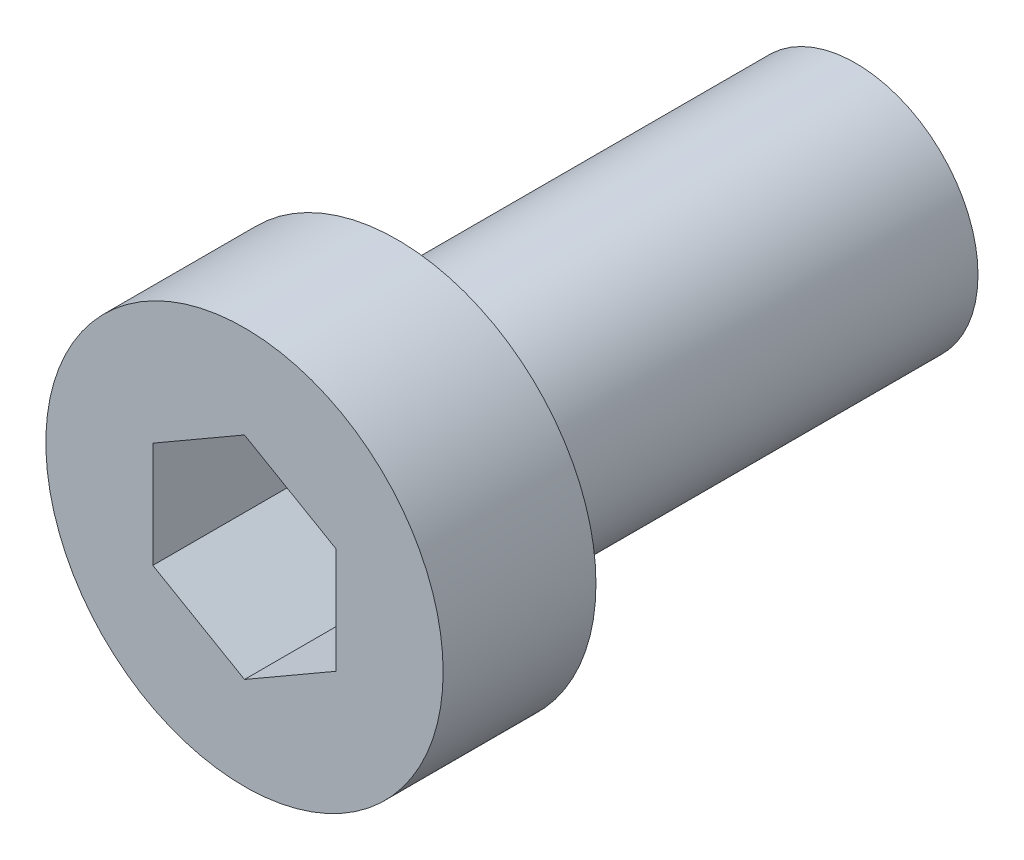
from build123d import *

# Parameters (mm, degrees)
SKETCH1_R           = 6.5
BASE_EXTRUDE_DEPTH  = 5
SKETCH2_R           = 4
BOSS_EXTRUDE1_DEPTH = 15
CUT_EXTRUDE1_DEPTH  = 5


with BuildPart() as part:
    # Sketch1 → Base-Extrude (new body)
    with BuildSketch(Plane.XY):
        Circle(SKETCH1_R)
    extrude(amount=BASE_EXTRUDE_DEPTH)

    # Sketch2 → Boss-Extrude1 (add)
    with BuildSketch(Plane(origin=(0, 0, 0), x_dir=(-1, 0, 0), z_dir=(0, 0, -1))):
        Circle(SKETCH2_R)
    extrude(amount=BOSS_EXTRUDE1_DEPTH)

    # Sketch3 → Cut-Extrude1 (cut)
    with BuildSketch(Plane.XY.offset(5)):
        Polygon((0, 3.464101615), (-3, 1.732050808), (-3, -1.732050808), (0, -3.464101615), (3, -1.732050808), (3, 1.732050808), align=None)
    extrude(amount=-CUT_EXTRUDE1_DEPTH, mode=Mode.SUBTRACT)


solid = part.part
